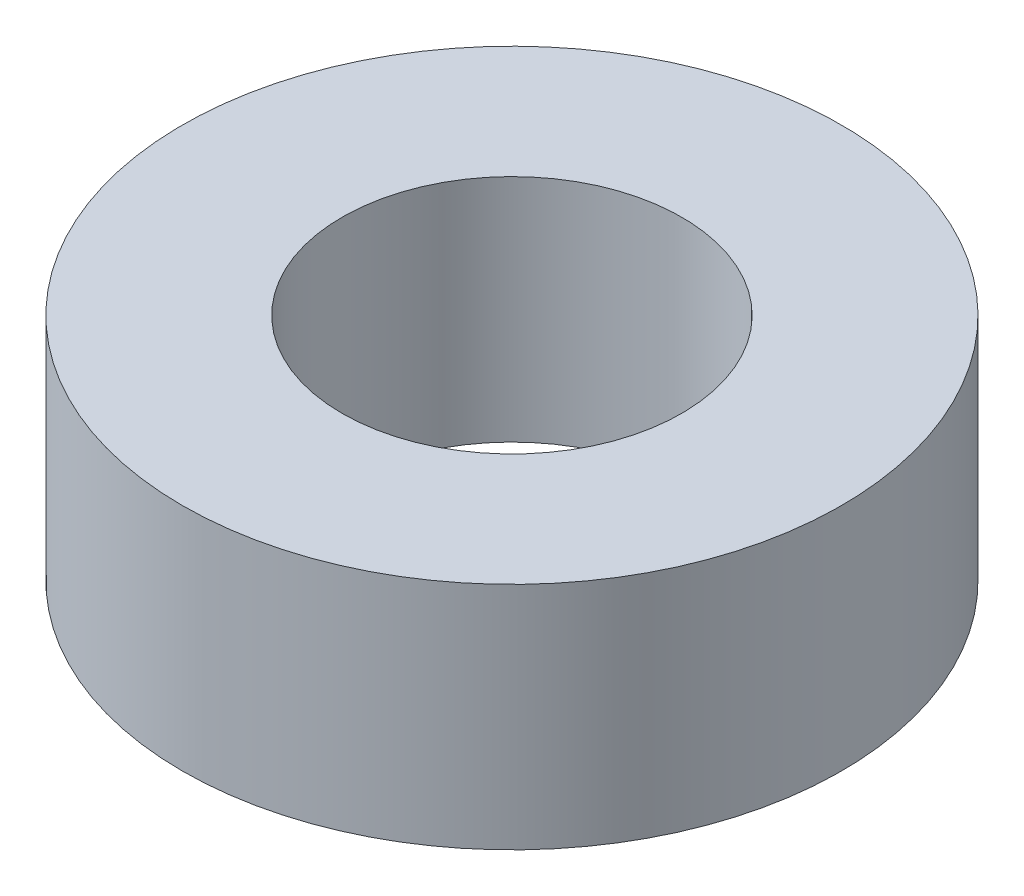
from build123d import *

# Parameters (mm, degrees)
SKETCH1_R           = 6.5532
SKETCH1_R_2         = 3.3782
BOSS_EXTRUDE1_DEPTH = 4.572


with BuildPart() as part:
    # Sketch1 → Boss-Extrude1 (new body)
    with BuildSketch(Plane(origin=(0, 0, 0), x_dir=(1, 0, 0), z_dir=(0, 1, 0))):
        Circle(SKETCH1_R)
        Circle(SKETCH1_R_2, mode=Mode.SUBTRACT)
    extrude(amount=BOSS_EXTRUDE1_DEPTH)


solid = part.part
